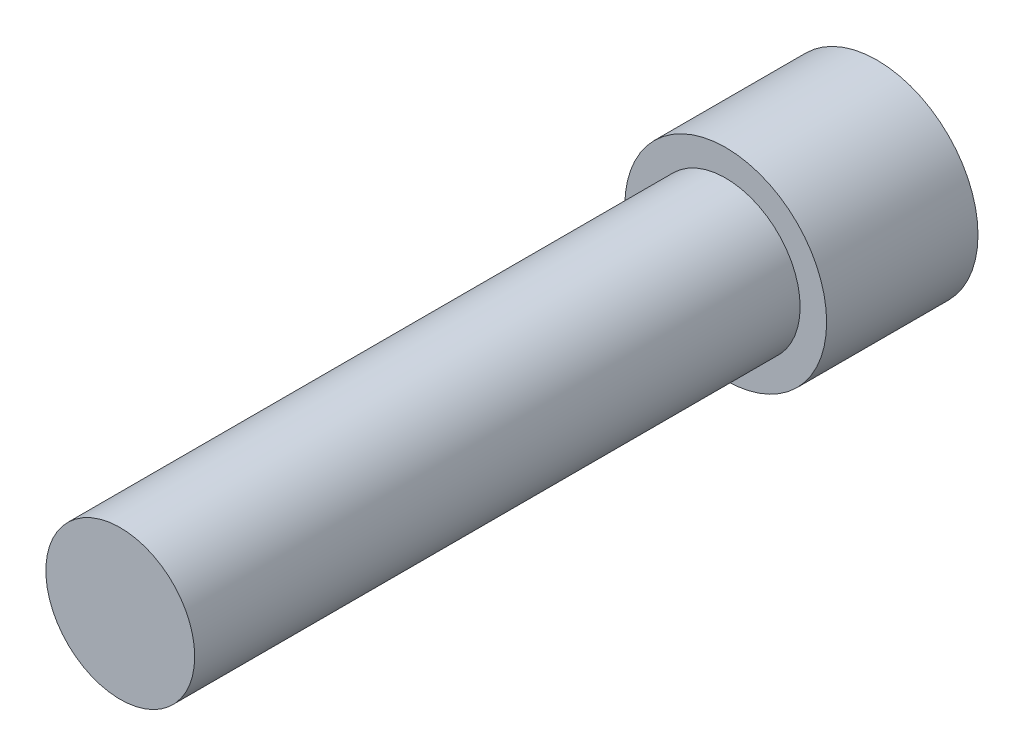
from build123d import *

# Parameters (mm, degrees)
SKETCH1_R      = 2
EXTRUDE1_DEPTH = 3
EXTRUDE3_DEPTH = 1.82
SKETCH2_R      = 1.475
EXTRUDE2_DEPTH = 12


with BuildPart() as part:
    # Sketch1 → Extrude1 (new body)
    with BuildSketch(Plane.XY):
        Circle(SKETCH1_R)
    extrude(amount=EXTRUDE1_DEPTH)

    # Sketch3 → Extrude3 (cut)
    with BuildSketch(Plane(origin=(0, 0, 0), x_dir=(-1, 0, 0), z_dir=(0, 0, -1))):
        Polygon((-1.443375673, 0), (-0.721687836, -1.25), (0.721687836, -1.25), (1.443375673, 0), (0.721687836, 1.25), (-0.721687836, 1.25), align=None)
    extrude(amount=-EXTRUDE3_DEPTH, mode=Mode.SUBTRACT)

    # Sketch2 → Extrude2 (add)
    with BuildSketch(Plane.XY.offset(3)):
        Circle(SKETCH2_R)
    extrude(amount=EXTRUDE2_DEPTH)


solid = part.part
